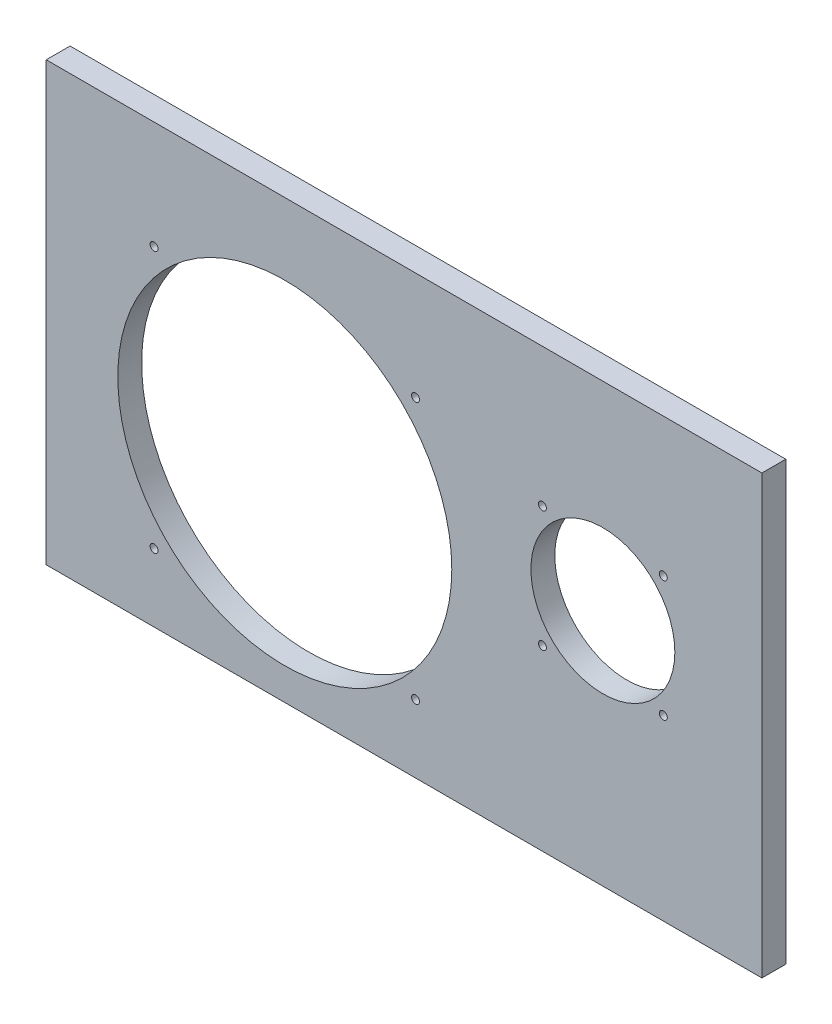
from build123d import *

# Parameters (mm, degrees)
SKETCH1_W           = 180
SKETCH1_H           = 110
SKETCH1_R           = 42
SKETCH1_R_2         = 18.1
BOSS_EXTRUDE1_DEPTH = 6
SKETCH3_R           = 1
CUT_EXTRUDE1_DEPTH  = 30


with BuildPart() as part:
    # Sketch1 → Boss-Extrude1 (new body)
    with BuildSketch(Plane.XY):
        with Locations((90, 55)):
            Rectangle(SKETCH1_W, SKETCH1_H)
        with Locations((60, 50)):
            Circle(SKETCH1_R, mode=Mode.SUBTRACT)
        with Locations((140, 60)):
            Circle(SKETCH1_R_2, mode=Mode.SUBTRACT)
    extrude(amount=BOSS_EXTRUDE1_DEPTH)

    # Sketch3 → Cut-Extrude1 (cut)
    with BuildSketch(Plane.XY):
        with Locations((92.880465325, 82.880465325)):
            Circle(SKETCH3_R)
        with Locations((27.119534675, 82.880465325)):
            Circle(SKETCH3_R)
        with Locations((27.119534675, 17.119534675)):
            Circle(SKETCH3_R)
        with Locations((92.880465325, 17.119534675)):
            Circle(SKETCH3_R)
        with Locations((155.202795796, 75.202795796)):
            Circle(SKETCH3_R)
        with Locations((124.797204204, 75.202795796)):
            Circle(SKETCH3_R)
        with Locations((124.797204204, 44.797204204)):
            Circle(SKETCH3_R)
        with Locations((155.202795796, 44.797204204)):
            Circle(SKETCH3_R)
    extrude(amount=CUT_EXTRUDE1_DEPTH, mode=Mode.SUBTRACT)


solid = part.part
